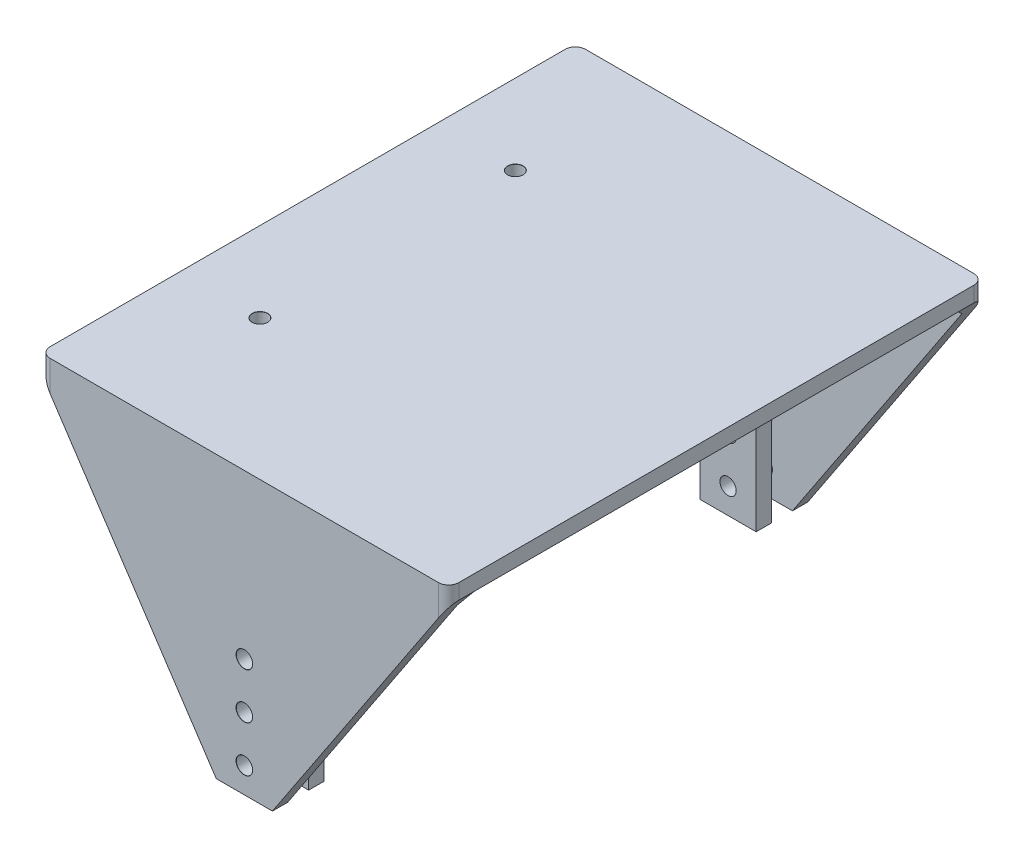
from build123d import *

# Parameters (mm, degrees)
SKETCH1_W                       = 80
SKETCH1_H                       = 98.8
BOSS_EXTRUDE1_DEPTH             = 3
BOSS_EXTRUDE2_DEPTH             = 3
CHAMFER2_SIZE                   = 2
FILLET1_R                       = 2
SKETCH4_W                       = 11
SKETCH4_H                       = 3
BOSS_EXTRUDE3_DEPTH             = 4.1
SKETCH6_W                       = 11
SKETCH6_H                       = 32.1
BOSS_EXTRUDE4_DEPTH             = 3
CHAMFER3_SIZE                   = 2
F_3_0MM_DOWEL_HOLE1_D           = 3.2
F_3_0MM_DOWEL_HOLE1_CSINK_D     = 3.25
F_3_0MM_DOWEL_HOLE1_CSINK_ANGLE = 90
F_3_0MM_DOWEL_HOLE2_D           = 3
F_3_0MM_DOWEL_HOLE2_DEPTH       = 20
F_3_0MM_DOWEL_HOLE2_CSINK_D     = 3.05
F_3_0MM_DOWEL_HOLE2_CSINK_ANGLE = 90
F_3_0MM_DOWEL_HOLE2_TIP         = 0.901290929


with BuildPart() as part:
    # Sketch1 → Boss-Extrude1 (new body)
    with BuildSketch(Plane(origin=(0, 0, 0), x_dir=(1, 0, 0), z_dir=(0, 1, 0))):
        Rectangle(SKETCH1_W, SKETCH1_H)
    extrude(amount=BOSS_EXTRUDE1_DEPTH)

    # Sketch3 → Boss-Extrude2 (add)
    with BuildSketch(Plane.XY.offset(49.4)):
        Polygon((-40, 0), (-40, 3), (40, 3), (40, 0), (5.5, -52), (-5.5, -52), align=None)
    boss_extrude2 = extrude(amount=BOSS_EXTRUDE2_DEPTH)

    # Mirror1: Boss-Extrude2 across plane
    add(boss_extrude2.mirror(Plane.XY))

    # Chamfer2
    chamfer2_edges = [part.edges().sort_by_distance(p)[0] for p in [
        (0, 0, 49.4),
        (0, 0, -49.4),
    ]]
    chamfer(chamfer2_edges, length=CHAMFER2_SIZE)

    # Fillet1
    fillet1_edges = [part.edges().sort_by_distance(p)[0] for p in [
        (40, 1.5, 52.4),
        (-40, 1.5, 52.4),
        (-40, 1.5, -52.4),
        (40, 1.5, -52.4),
    ]]
    fillet(fillet1_edges, radius=FILLET1_R)

    # Sketch4 → Boss-Extrude3 (add)
    with BuildSketch(Plane(origin=(0, 0, 49.4), x_dir=(-1, 0, 0), z_dir=(0, 0, -1))):
        with Locations((0, -21.4)):
            Rectangle(SKETCH4_W, SKETCH4_H)
    boss_extrude3 = extrude(amount=BOSS_EXTRUDE3_DEPTH)

    # Sketch6 → Boss-Extrude4 (add)
    with BuildSketch(Plane(origin=(0, 0, 45.3), x_dir=(-1, 0, 0), z_dir=(0, 0, -1))):
        with Locations((0, -35.95)):
            Rectangle(SKETCH6_W, SKETCH6_H)
    boss_extrude4 = extrude(amount=BOSS_EXTRUDE4_DEPTH)

    # Mirror4: Boss-Extrude3, Boss-Extrude4 across plane
    add(boss_extrude3.mirror(Plane.XY))
    add(boss_extrude4.mirror(Plane.XY))

    # Chamfer3
    chamfer3_edges = [part.edges().sort_by_distance(p)[0] for p in [
        (0, -19.9, 49.4),
        (0, -19.9, -49.4),
    ]]
    chamfer(chamfer3_edges, length=CHAMFER3_SIZE)

    # Ø3.0mm Dowel Hole1 (through all)
    with Locations(Plane.XY.offset(52.4)):
        with Locations((0, -47), (0, -38), (0, -29)):
            CounterSinkHole(F_3_0MM_DOWEL_HOLE1_D / 2, F_3_0MM_DOWEL_HOLE1_CSINK_D / 2, counter_sink_angle=F_3_0MM_DOWEL_HOLE1_CSINK_ANGLE)

    # Ø3.0mm Dowel Hole2
    with Locations(Plane(origin=(0, 3, 0), x_dir=(1, 0, 0), z_dir=(0, 1, 0))):
        with Locations((-24.35, 25), (-24.35, -25)):
            CounterSinkHole(F_3_0MM_DOWEL_HOLE2_D / 2, F_3_0MM_DOWEL_HOLE2_CSINK_D / 2, depth=F_3_0MM_DOWEL_HOLE2_DEPTH, counter_sink_angle=F_3_0MM_DOWEL_HOLE2_CSINK_ANGLE)
            with Locations((0, 0, -(F_3_0MM_DOWEL_HOLE2_DEPTH + F_3_0MM_DOWEL_HOLE2_TIP / 2))):  # 118° drill point
                Cone(0, F_3_0MM_DOWEL_HOLE2_D / 2, F_3_0MM_DOWEL_HOLE2_TIP, mode=Mode.SUBTRACT)


solid = part.part
